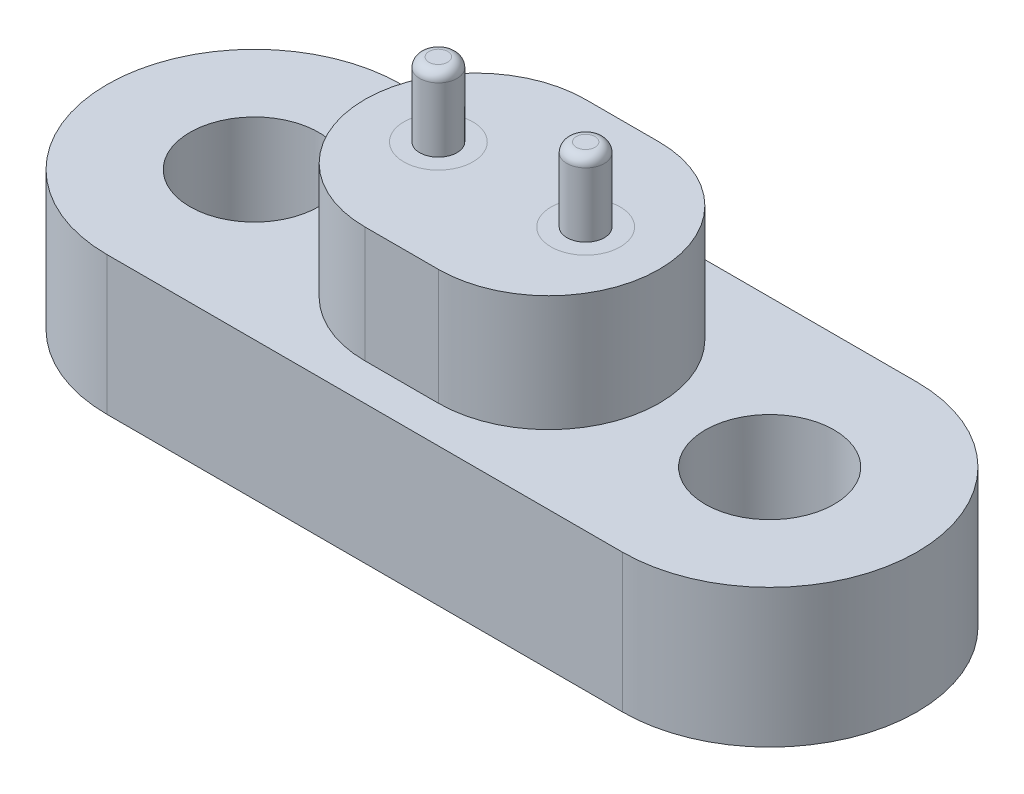
from build123d import *

# Parameters (mm, degrees)
BOSS_EXTRUDE1_DEPTH   = 3.7592
SKETCH2_R             = 0.9398
BOSS_EXTRUDE2_DEPTH   = 3.1496
SKETCH3_R             = 0.9398
BOSS_EXTRUDE3_DEPTH   = 6.985
BOSS_EXTRUDE3_2_DEPTH = 6.985
SKETCH4_R             = 0.508
BOSS_EXTRUDE4_DEPTH   = 2
BOSS_EXTRUDE4_2_DEPTH = 2
FILLET1_R             = 0.254
FILLET2_R             = 0.254
SKETCH5_R             = 1.75
CUT_EXTRUDE1_DEPTH    = 4.8354


with BuildPart() as part:
    # Sketch1 → Boss-Extrude1 (new body)
    with BuildSketch(Plane(origin=(0, 0, 0), x_dir=(1, 0, 0), z_dir=(0, 1, 0))):
        with BuildLine():
            Line((-6.99897, 4.0005), (6.99897, 4.0005))
            ThreePointArc((6.99897, 4.0005), (10.99947, 0), (6.99897, -4.0005))
            Line((6.99897, -4.0005), (-6.99897, -4.0005))
            ThreePointArc((-6.99897, -4.0005), (-10.99947, 0), (-6.99897, 4.0005))
        make_face()
    extrude(amount=BOSS_EXTRUDE1_DEPTH)

    # Sketch2 → Boss-Extrude2 (add)
    with BuildSketch(Plane(origin=(0, 3.7592, 0), x_dir=(1, 0, 0), z_dir=(0, 1, 0))):
        with BuildLine():
            Line((-1, 2.9972), (1, 2.9972))
            ThreePointArc((1, 2.9972), (3.9972, 0), (1, -2.9972))
            Line((1, -2.9972), (-1, -2.9972))
            ThreePointArc((-1, -2.9972), (-3.9972, 0), (-1, 2.9972))
        make_face()
        with Locations((-2.00025, 0)):
            Circle(SKETCH2_R, mode=Mode.SUBTRACT)
        with Locations((2.00025, 0)):
            Circle(SKETCH2_R, mode=Mode.SUBTRACT)
    extrude(amount=BOSS_EXTRUDE2_DEPTH)

    # Sketch5 → Cut-Extrude1 (cut, through all)
    with BuildSketch(Plane(origin=(0, 3.7592, 0), x_dir=(1, 0, 0), z_dir=(0, 1, 0))):
        with Locations((-6.99897, 0)):
            Circle(SKETCH5_R)
        with Locations((6.99897, 0)):
            Circle(SKETCH5_R)
    extrude(amount=-CUT_EXTRUDE1_DEPTH, mode=Mode.SUBTRACT)


with BuildPart() as body_2:
    # Sketch3 → Boss-Extrude3 (new body)
    with BuildSketch(Plane(origin=(0, 6.9088, 0), x_dir=(1, 0, 0), z_dir=(0, 1, 0))):
        with Locations((-2.00025, 0)):
            Circle(SKETCH3_R)
    extrude(amount=-BOSS_EXTRUDE3_DEPTH)


with BuildPart() as body_3:
    # Sketch3 → Boss-Extrude3 2 (new body)
    with BuildSketch(Plane(origin=(0, 6.9088, 0), x_dir=(1, 0, 0), z_dir=(0, 1, 0))):
        with Locations((2.00025, 0)):
            Circle(SKETCH3_R)
    extrude(amount=-BOSS_EXTRUDE3_2_DEPTH)


with BuildPart() as body_4:
    # Sketch4 → Boss-Extrude4 (new body)
    with BuildSketch(Plane.XZ.offset(-6.9088)):
        with Locations((-2.00025, 0)):
            Circle(SKETCH4_R)
    extrude(amount=-BOSS_EXTRUDE4_DEPTH)

    # Fillet1
    fillet1_edges = [body_4.edges().sort_by_distance(p)[0] for p in [
        (-2.50825, 8.9088, 0),
    ]]
    fillet(fillet1_edges, radius=FILLET1_R)


with BuildPart() as body_5:
    # Sketch4 → Boss-Extrude4 2 (new body)
    with BuildSketch(Plane.XZ.offset(-6.9088)):
        with Locations((2.00025, 0)):
            Circle(SKETCH4_R)
    extrude(amount=-BOSS_EXTRUDE4_2_DEPTH)

    # Fillet2
    fillet2_edges = [body_5.edges().sort_by_distance(p)[0] for p in [
        (1.49225, 8.9088, 0),
    ]]
    fillet(fillet2_edges, radius=FILLET2_R)


solid = Compound([part.part, body_2.part, body_3.part, body_4.part, body_5.part])
